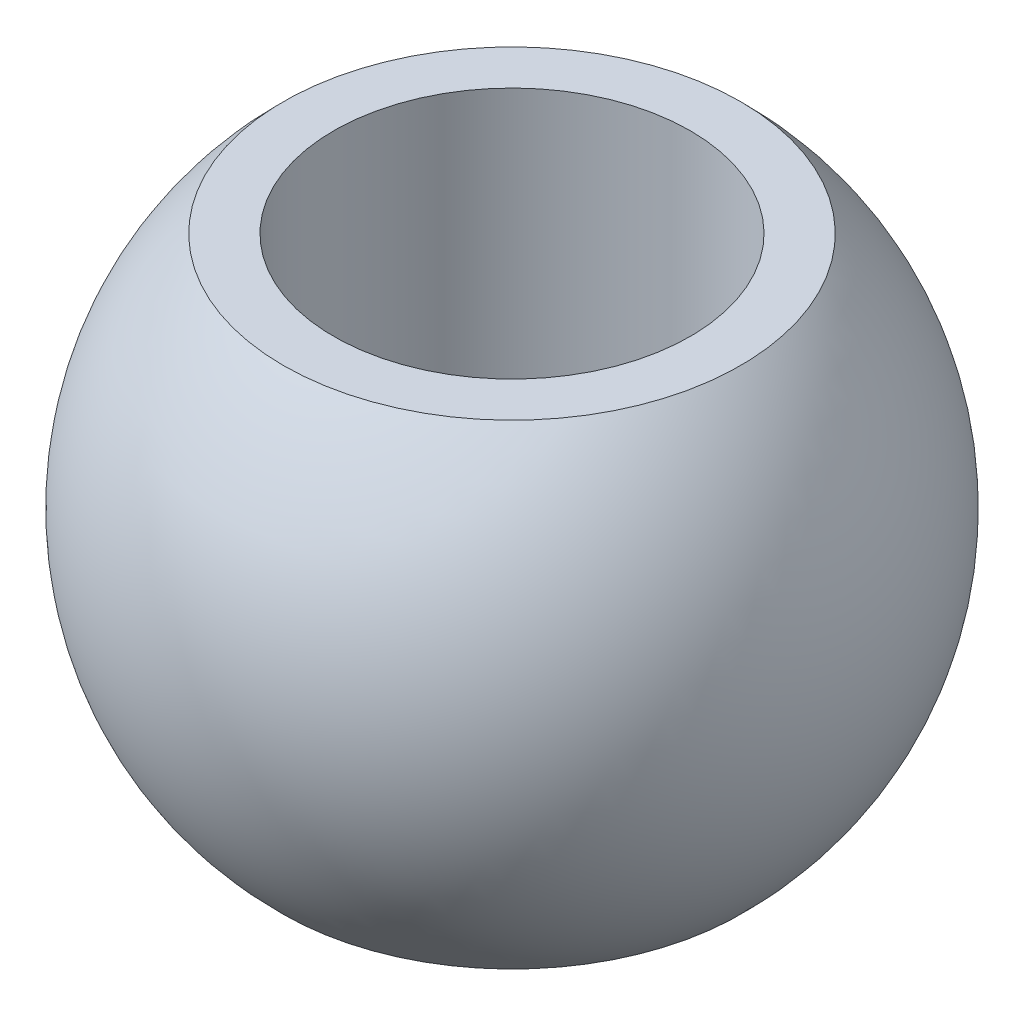
from build123d import *


with BuildPart() as part:
    # Szkic1 → Obrót1 (revolve)
    with BuildSketch(Plane.XY):
        with BuildLine():
            Line((6, -8), (6, 8))
            Line((6, 8), (7.694803441, 8))
            ThreePointArc((7.694803441, 8), (11.1, 0), (7.694803441, -8))
            Line((7.694803441, -8), (6, -8))
        make_face()
    revolve(axis=Axis((0, -11.1, 0), (0, 1, 0)))


solid = part.part
